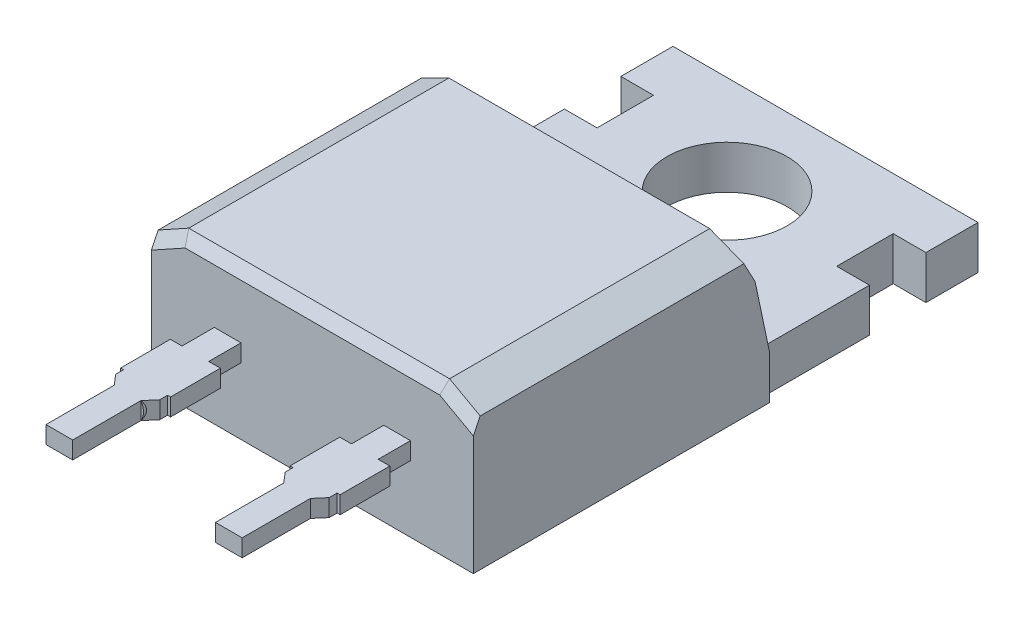
from build123d import *
from OCP.BRepFilletAPI import BRepFilletAPI_MakeChamfer

# Parameters (mm, degrees)
EXTRUDE1_DEPTH        = 4.826
EXTRUDE1_DEPTH_BACK   = 4.826
SKETCH10_R            = 1.8
SKETCH10_W            = 1.233836604
SKETCH10_H            = 1.6931216
EXTRUDE5_DEPTH        = 16.428369203
SKETCH6_W             = 0.8
SKETCH6_H             = 0.52
EXTRUDE6_DEPTH        = 13
EXTRUDE7_START        = -0.52
EXTRUDE7_DEPTH        = 0.52
CHAMFER1_SIZE         = 0.254
SKETCH12_W            = 7.379682426
SKETCH12_H            = 2.736118788
EXTRUDE8_DEPTH        = 0.254
SKETCH13_W            = 7.379682426
SKETCH13_H            = 2.736118788
EXTRUDE9_DEPTH        = 0.254
CHAMFER2_SIZE         = 0.508
CHAMFER2_SIZE2        = 0.91645626
CHAMFER3_SIZE         = 0.2032
CHAMFER3_SIZE2        = 0.366582504
CHAMFER3_SIZE2_2      = 0.605677555
CHAMFER3_SIZE2_3      = 0.557834937
EXTRUDE10_DEPTH       = 1.016
ESBO_O1_W             = 2.508369598
ESBO_O1_H             = 14.0227971
CORTE_EXTRUS_O1_DEPTH = 2.54
SKETCH17_W            = 14.984360746
SKETCH17_H            = 12.426120952
CUT_EXTRUDE1_DEPTH    = 22.464410101


with BuildPart() as part:
    # Sketch2 → Extrude1 (new, two sides)
    with BuildSketch(Plane(origin=(0, 0, 0), x_dir=(0, 0, -1), z_dir=(1, 0, 0))) as extrude1_sk:
        Polygon((14.3005, 0), (-1.0795, 0), (-1.0795, 4.5), (7.124012877, 4.5), (7.8005, 1.3), (14.3005, 1.3), align=None)
    extrude(amount=EXTRUDE1_DEPTH)
    extrude(extrude1_sk.sketch, amount=-EXTRUDE1_DEPTH_BACK)

    # Sketch10 → Extrude5 (cut, through all)
    with BuildSketch(Plane(origin=(0, 1.3, 0), x_dir=(1, 0, 0), z_dir=(0, 1, 0))):
        with Locations(Location((0, 11.3505, 0), (0, 0, 270))):
            Circle(SKETCH10_R)
        with Locations((-4.209081698, 11.892729701)):
            Rectangle(SKETCH10_W, SKETCH10_H)
        with Locations((4.209081698, 11.892729701)):
            Rectangle(SKETCH10_W, SKETCH10_H)
    extrude(amount=-EXTRUDE5_DEPTH, mode=Mode.SUBTRACT)

    # Sketch6 → Extrude6 (add)
    with BuildSketch(Plane.XY.offset(1.0795)):
        with Locations((2.54, 2.25)):
            Rectangle(SKETCH6_W, SKETCH6_H)
        with Locations((-2.54, 2.25)):
            Rectangle(SKETCH6_W, SKETCH6_H)
        with Locations((0, 2.25)):
            Rectangle(SKETCH6_W, SKETCH6_H)
    extrude(amount=EXTRUDE6_DEPTH)

    # Sketch11 → Extrude7 (add)
    with BuildSketch(Plane(origin=(0, 2.51, 0), x_dir=(1, 0, 0), z_dir=(0, 1, 0)).offset(EXTRUDE7_START)):
        Polygon((-2.94, -2.0475), (-3.29, -2.0475), (-3.29, -3.5395), (-3.2004, -3.5395), (-3.2004, -3.7747), (-2.94, -4.0795), align=None)
        Polygon((-1.79, -2.0475), (-2.14, -2.0475), (-2.14, -4.0795), (-1.8796, -3.7747), (-1.8796, -3.5395), (-1.79, -3.5395), align=None)
        Polygon((-0.4, -2.0475), (-0.75, -2.0475), (-0.75, -3.5395), (-0.6604, -3.5395), (-0.6604, -3.7747), (-0.4, -4.0795), align=None)
        Polygon((0.75, -2.0475), (0.4, -2.0475), (0.4, -4.0795), (0.6604, -3.7747), (0.6604, -3.5395), (0.75, -3.5395), align=None)
        Polygon((2.14, -2.0475), (1.79, -2.0475), (1.79, -3.5395), (1.8796, -3.5395), (1.8796, -3.7747), (2.14, -4.0795), align=None)
        Polygon((3.29, -2.0475), (2.94, -2.0475), (2.94, -4.0795), (3.2004, -3.7747), (3.2004, -3.5395), (3.29, -3.5395), align=None)
    extrude(amount=EXTRUDE7_DEPTH)

    # Chamfer1
    chamfer1_edges = [part.edges().sort_by_distance(p)[0] for p in [
        (-2.14, 2.25, 14.0795),
        (-2.94, 2.25, 14.0795),
        (2.94, 2.25, 14.0795),
        (2.14, 2.25, 14.0795),
        (0.4, 2.25, 14.0795),
        (-0.4, 2.25, 14.0795),
    ]]
    chamfer(chamfer1_edges, length=CHAMFER1_SIZE)

    # Sketch12 → Extrude8 (cut)
    with BuildSketch(Plane.ZY.offset(4.826)):
        with Locations((-11.490341213, 1.368059394)):
            Rectangle(SKETCH12_W, SKETCH12_H)
    extrude(amount=-EXTRUDE8_DEPTH, mode=Mode.SUBTRACT)

    # Sketch13 → Extrude9 (cut)
    with BuildSketch(Plane(origin=(4.826, 0, 0), x_dir=(0, 0, -1), z_dir=(1, 0, 0))):
        with Locations((11.490341213, 1.368059394)):
            Rectangle(SKETCH13_W, SKETCH13_H)
    extrude(amount=-EXTRUDE9_DEPTH, mode=Mode.SUBTRACT)

    # Chamfer2: one chamfer whose edges measure the first distance from different faces: ONE call of the kernel's chamfer builder (chamfer() names one face for all edges)
    chamfer2_edges_1 = [part.edges().sort_by_distance(p)[0] for p in [
        (-4.826, 4.5, -3.022256439),
    ]]
    chamfer2_side_1 = [part.faces().sort_by_distance(p)[0] for p in [
        (-4.826, 2.217055195, -3.243165334),
    ]]
    chamfer2_edges_2 = [part.edges().sort_by_distance(p)[0] for p in [
        (4.826, 4.5, -3.022256439),
    ]]
    chamfer2_side_2 = [part.faces().sort_by_distance(p)[0] for p in [
        (4.826, 2.217055195, -3.243165334),
    ]]
    chamfer2 = BRepFilletAPI_MakeChamfer(part.part.solid().wrapped)
    for e in chamfer2_edges_1:
        chamfer2.Add(CHAMFER2_SIZE, CHAMFER2_SIZE2, e.wrapped, chamfer2_side_1[0].wrapped)  # the first distance lies on this face
    for e in chamfer2_edges_2:
        chamfer2.Add(CHAMFER2_SIZE, CHAMFER2_SIZE2, e.wrapped, chamfer2_side_2[0].wrapped)  # the first distance lies on this face
    add(Compound.cast(chamfer2.Shape()), mode=Mode.REPLACE)

    # Chamfer3: one chamfer whose edges measure the first distance from different faces: ONE call of the kernel's chamfer builder (chamfer() names one face for all edges)
    chamfer3_edges_1 = [part.edges().sort_by_distance(p)[0] for p in [
        (0, 4.5, 1.0795),
    ]]
    chamfer3_side_1 = [part.faces().sort_by_distance(p)[0] for p in [
        (0, 4.5, -3.022256439),
    ]]
    chamfer3_edges_2 = [part.edges().sort_by_distance(p)[0] for p in [
        (-4.36777187, 4.246, 1.0795),
    ]]
    chamfer3_side_2 = [part.faces().sort_by_distance(p)[0] for p in [
        (-4.368765147, 4.245449417, -3.049162718),
    ]]
    chamfer3_edges_3 = [part.edges().sort_by_distance(p)[0] for p in [
        (4.36777187, 4.246, 1.0795),
    ]]
    chamfer3_side_3 = [part.faces().sort_by_distance(p)[0] for p in [
        (4.368765147, 4.245449417, -3.049162718),
    ]]
    chamfer3_edges_4 = [part.edges().sort_by_distance(p)[0] for p in [
        (0, 4.5, -7.124012877),
    ]]
    chamfer3_side_4 = [part.faces().sort_by_distance(p)[0] for p in [
        (0, 4.5, -3.022256439),
    ]]
    chamfer3_edges_5 = [part.edges().sort_by_distance(p)[0] for p in [
        (-4.36777187, 4.246, -7.177709043),
    ]]
    chamfer3_side_5 = [part.faces().sort_by_distance(p)[0] for p in [
        (-4.368765147, 4.245449417, -3.049162718),
    ]]
    chamfer3_edges_6 = [part.edges().sort_by_distance(p)[0] for p in [
        (4.36777187, 4.246, -7.177709043),
    ]]
    chamfer3_side_6 = [part.faces().sort_by_distance(p)[0] for p in [
        (4.368765147, 4.245449417, -3.049162718),
    ]]
    chamfer3 = BRepFilletAPI_MakeChamfer(part.part.solid().wrapped)
    for e in chamfer3_edges_1:
        chamfer3.Add(CHAMFER3_SIZE, CHAMFER3_SIZE2, e.wrapped, chamfer3_side_1[0].wrapped)  # the first distance lies on this face
    for e in chamfer3_edges_2:
        chamfer3.Add(CHAMFER3_SIZE, CHAMFER3_SIZE2, e.wrapped, chamfer3_side_2[0].wrapped)  # the first distance lies on this face
    for e in chamfer3_edges_3:
        chamfer3.Add(CHAMFER3_SIZE, CHAMFER3_SIZE2, e.wrapped, chamfer3_side_3[0].wrapped)  # the first distance lies on this face
    for e in chamfer3_edges_4:
        chamfer3.Add(CHAMFER3_SIZE, CHAMFER3_SIZE2_2, e.wrapped, chamfer3_side_4[0].wrapped)  # the first distance lies on this face
    for e in chamfer3_edges_5:
        chamfer3.Add(CHAMFER3_SIZE, CHAMFER3_SIZE2_3, e.wrapped, chamfer3_side_5[0].wrapped)  # the first distance lies on this face
    for e in chamfer3_edges_6:
        chamfer3.Add(CHAMFER3_SIZE, CHAMFER3_SIZE2_3, e.wrapped, chamfer3_side_6[0].wrapped)  # the first distance lies on this face
    add(Compound.cast(chamfer3.Shape()), mode=Mode.REPLACE)

    # Sketch15 → Extrude10 (add)
    with BuildSketch(Plane.XY.offset(4.0795)):
        with BuildLine():
            Line((-2.14, 2.51), (-2.94, 2.51))
            ThreePointArc((-2.94, 2.51), (-3.017074418, 2.25), (-2.94, 1.99))
            Line((-2.94, 1.99), (-2.14, 1.99))
            ThreePointArc((-2.14, 1.99), (-2.062925582, 2.25), (-2.14, 2.51))
        make_face()
    extrude(amount=-EXTRUDE10_DEPTH)

    # Esboço1 → Corte-extrusão1 (cut)
    with BuildSketch(Plane(origin=(0, 2.51, 0), x_dir=(1, 0, 0), z_dir=(0, 1, 0))):
        with Locations((0.046451289, -8.09089855)):
            Rectangle(ESBO_O1_W, ESBO_O1_H)
    extrude(amount=-CORTE_EXTRUS_O1_DEPTH, mode=Mode.SUBTRACT)

    # Sketch17 → Cut-Extrude1 (cut, through all)
    with BuildSketch(Plane.XY.offset(6.1245)):
        Rectangle(SKETCH17_W, SKETCH17_H)
    extrude(amount=CUT_EXTRUDE1_DEPTH, mode=Mode.SUBTRACT)


solid = part.part
